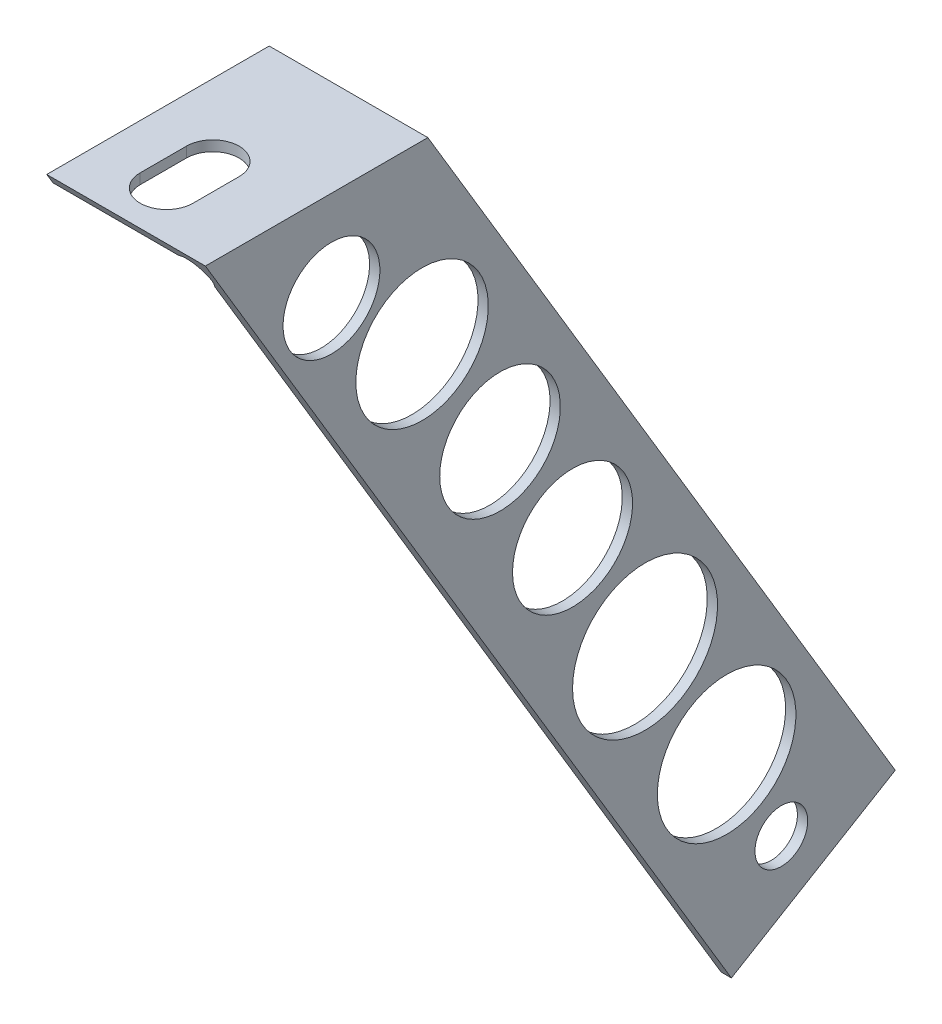
from build123d import *

# Parameters (mm, degrees)
SKETCH1_R                = 4.064
BOSS_EXTRUDE1_DEPTH      = 2.032
SKETCH2_R                = 4.064
BOSS_EXTRUDE2_DEPTH      = 2.032
FILLET1_R                = 2.032
BOSS_EXTRUDE3_DEPTH      = 58.42
BOSS_EXTRUDE3_DEPTH_BACK = 239.395
CUT_EXTRUDE1_DEPTH       = 1
CUT_EXTRUDE1_DEPTH_BACK  = 483.6
CUT_EXTRUDE2_DEPTH       = 25.4475
SKETCH7_R                = 4.064
CUT_EXTRUDE3_DEPTH       = 25.4475
SKETCH8_R                = 4.064
CUT_EXTRUDE4_DEPTH       = 136.562269206
SKETCH10_R               = 10.67677981
SKETCH10_R_2             = 9.251177106
SKETCH10_R_3             = 9.294395921
SKETCH10_R_4             = 10.207707861
SKETCH10_R_5             = 7.460626698
SKETCH10_R_6             = 11.174016497
CUT_EXTRUDE5_DEPTH       = 2.5875


with BuildPart() as part:
    # Sketch1 → Boss-Extrude1 (new body)
    with BuildSketch(Plane(origin=(0, 0, 0), x_dir=(0, 0, -1), z_dir=(1, 0, 0))):
        Polygon((-193.675, 0), (193.675, 0), (239.395, -132.715), (239.395, -161.29), (-243.205, -161.29), (-243.205, -132.715), align=None)
        with Locations((219.075, -116.84)):
            Circle(SKETCH1_R, mode=Mode.SUBTRACT)
    extrude(amount=BOSS_EXTRUDE1_DEPTH)

    # Sketch2 → Boss-Extrude2 (add)
    with BuildSketch(Plane(origin=(0, 0, 0), x_dir=(1, 0, 0), z_dir=(0, 1, 0))):
        Polygon((2.032, -193.675), (2.032, 193.675), (0, 193.675), (-20.828, 165.1), (-20.828, -165.1), (0, -193.675), align=None)
        with Locations((-9.779, -32.7025)):
            Circle(SKETCH2_R, mode=Mode.SUBTRACT)
        with BuildLine():
            Line((-13.843, 144.8435), (-13.843, 137.7315))
            ThreePointArc((-13.843, 137.7315), (-9.779, 133.6675), (-5.715, 137.7315))
            Line((-5.715, 137.7315), (-5.715, 144.8435))
            ThreePointArc((-5.715, 144.8435), (-9.779, 148.9075), (-13.843, 144.8435))
        make_face(mode=Mode.SUBTRACT)
    extrude(amount=BOSS_EXTRUDE2_DEPTH)

    # Fillet1
    fillet1_edges = [part.edges().sort_by_distance(p)[0] for p in [
        (2.032, 2.032, 0),
    ]]
    fillet(fillet1_edges, radius=FILLET1_R)

    # Sketch3 → Boss-Extrude3 (add, two sides)
    with BuildSketch(Plane.XY) as boss_extrude3_sk:
        with BuildLine():
            Line((-1.376033354, 2.032), (-20.828, 2.032))
            Line((-20.828, 2.032), (-20.828, 3.6195))
            Line((-20.828, 3.6195), (3.6195, 3.6195))
            Line((3.6195, 3.6195), (3.6195, -161.29))
            Line((3.6195, -161.29), (2.032, -161.29))
            Line((2.032, -161.29), (2.032, -132.715))
            Line((2.032, -132.715), (2.032, -1.376033354))
            ThreePointArc((2.032, -1.376033354), (1.735294181, 1.735294181), (-1.376033354, 2.032))
        make_face()
    extrude(amount=BOSS_EXTRUDE3_DEPTH)
    extrude(boss_extrude3_sk.sketch, amount=-BOSS_EXTRUDE3_DEPTH_BACK)

    # Sketch4 → Cut-Extrude1 (cut, two sides)
    with BuildSketch(Plane(origin=(0, 0, -239.395), x_dir=(-1, 0, 0), z_dir=(0, 0, -1))) as cut_extrude1_sk:
        with BuildLine():
            Line((0, -161.29), (44.263147165, -161.29))
            Line((44.263147165, -161.29), (44.263147165, 7.390927462))
            Line((44.263147165, 7.390927462), (27.636319643, 7.390927462))
            Line((27.636319643, 7.390927462), (27.636319643, 2.032))
            Line((27.636319643, 2.032), (1.376033354, 2.032))
            ThreePointArc((1.376033354, 2.032), (-1.735294181, 1.735294181), (-2.032, -1.376033354))
            Line((-2.032, -1.376033354), (-2.032, -132.715))
            Line((-2.032, -132.715), (-2.032, -161.29))
            Line((-2.032, -161.29), (0, -161.29))
        make_face()
    extrude(amount=CUT_EXTRUDE1_DEPTH, mode=Mode.SUBTRACT)
    extrude(cut_extrude1_sk.sketch, amount=-CUT_EXTRUDE1_DEPTH_BACK, mode=Mode.SUBTRACT)

    # Sketch6 → Cut-Extrude2 (cut, through all)
    with BuildSketch(Plane(origin=(3.6195, 0, 0), x_dir=(0, 0, -1), z_dir=(1, 0, 0))):
        Polygon((164.593410128, 3.6195), (236.630427362, -116.84), (211.375744463, -131.942769206), (130.306990873, 3.6195), (-58.42, 3.6195), (-58.42, -161.29), (239.395, -161.29), (239.395, 3.6195), align=None)
    extrude(amount=-CUT_EXTRUDE2_DEPTH, mode=Mode.SUBTRACT)

    # Sketch7 → Cut-Extrude3 (cut, through all)
    with BuildSketch(Plane(origin=(3.6195, 0, 0), x_dir=(0, 0, -1), z_dir=(1, 0, 0))):
        with Locations((219.075, -116.84)):
            Circle(SKETCH7_R)
    extrude(amount=-CUT_EXTRUDE3_DEPTH, mode=Mode.SUBTRACT)

    # Sketch8 → Cut-Extrude4 (cut, through all)
    with BuildSketch(Plane(origin=(0, 3.6195, 0), x_dir=(1, 0, 0), z_dir=(0, 1, 0))):
        with Locations((-9.779, -32.7025)):
            Circle(SKETCH8_R)
        with BuildLine():
            Line((-13.843, 144.8435), (-13.843, 137.7315))
            ThreePointArc((-13.843, 137.7315), (-9.779, 133.6675), (-5.715, 137.7315))
            Line((-5.715, 137.7315), (-5.715, 144.8435))
            ThreePointArc((-5.715, 144.8435), (-9.779, 148.9075), (-13.843, 144.8435))
        make_face()
    extrude(amount=-CUT_EXTRUDE4_DEPTH, mode=Mode.SUBTRACT)

    # Sketch10 → Cut-Extrude5 (cut, through all)
    with BuildSketch(Plane.ZY.offset(-2.032)):
        with Locations((-210.642167036, -101.738031393)):
            Circle(SKETCH10_R)
        with Locations((-186.895001779, -60.948782833)):
            Circle(SKETCH10_R_2)
        with Locations((-175.719865187, -42.509807457)):
            Circle(SKETCH10_R_3)
        with Locations((-163.706593351, -23.512075251)):
            Circle(SKETCH10_R_4)
        with Locations((-149.737672611, -10.381289755)):
            Circle(SKETCH10_R_5)
        with Locations((-198.07013837, -81.064028698)):
            Circle(SKETCH10_R_6)
    extrude(amount=-CUT_EXTRUDE5_DEPTH, mode=Mode.SUBTRACT)


solid = part.part
